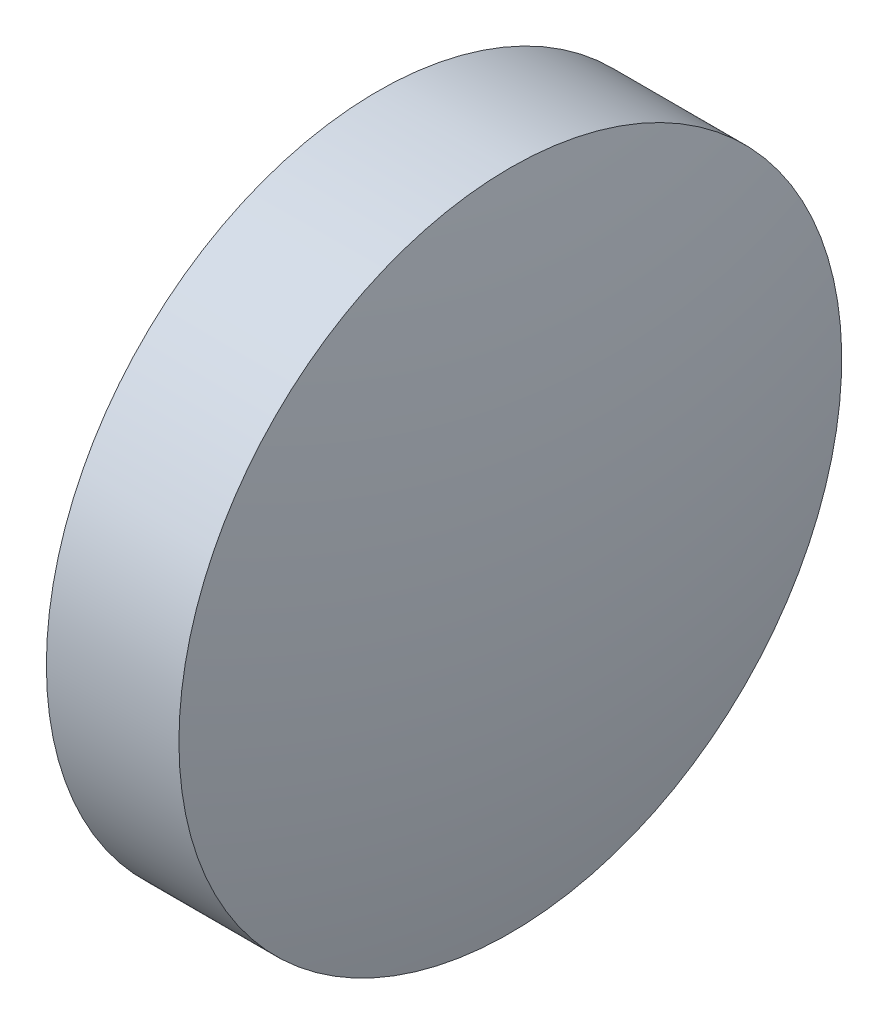
from build123d import *


with BuildPart() as part:
    # 草图1 → 旋转1 (revolve)
    with BuildSketch(Plane.XY):
        with BuildLine():
            Line((434.96555682, 64.002648692), (434.96555682, 69.002648692))
            Line((434.96555682, 69.002648692), (436.96555682, 69.002648692))
            ThreePointArc((436.96555682, 69.002648692), (437.385120512, 66.518279825), (437.52555682, 64.002648692))
            Line((437.52555682, 64.002648692), (434.96555682, 64.002648692))
        make_face()
    revolve(axis=Axis((433.823327128, 64.002648692, 0), (1, 0, 0)))


solid = part.part
